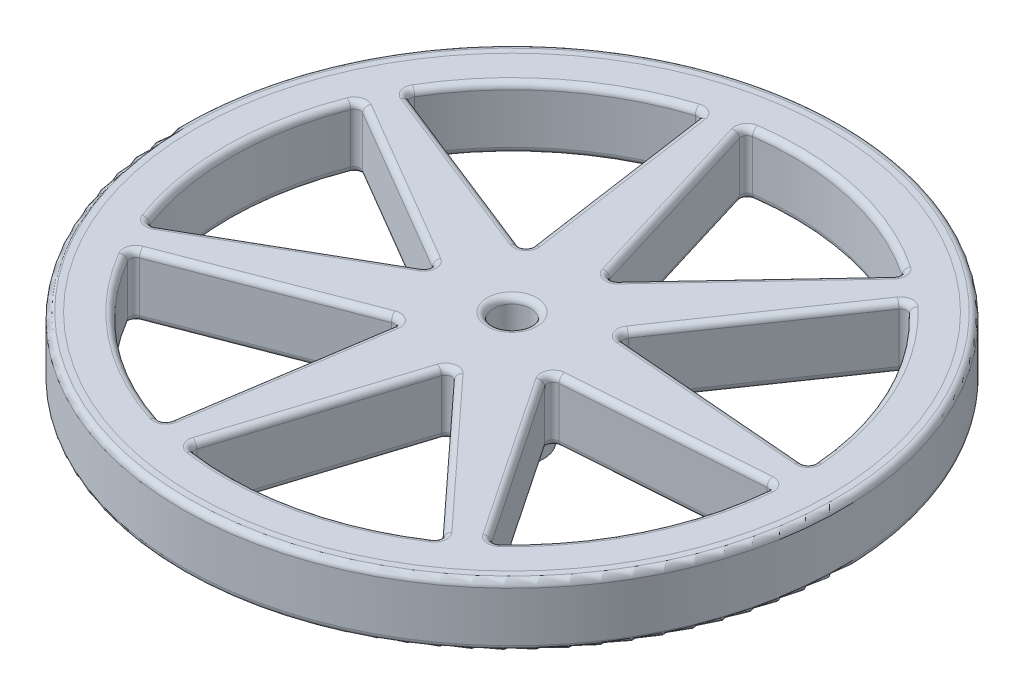
from build123d import *

# Parameters (mm, degrees)
SKETCH1_R               = 53
SKETCH1_R_2             = 52
BOSS_EXTRUDE1_DEPTH     = 10
SKETCH1_3_R             = 52
BOSS_EXTRUDE2_DEPTH     = 10
SKETCH1_4_R             = 5
SKETCH1_4_R_2           = 3
BOSS_EXTRUDE3_DEPTH     = 8
CUT_EXTRUDE1_DEPTH      = 76.617458302
CIRPATTERN1_COUNT       = 7
CUT_EXTRUDE2_DEPTH      = 76.617458302
CUT_EXTRUDE2_DEPTH_BACK = 76.617458302
SKETCH1_5_R             = 3
FILLET2_R               = 1


with BuildPart() as part:
    # Sketch1 → Boss-Extrude1 (new body)
    with BuildSketch(Plane(origin=(0, 0, 0), x_dir=(1, 0, 0), z_dir=(0, 1, 0))):
        Circle(SKETCH1_R)
        Circle(SKETCH1_R_2, mode=Mode.SUBTRACT)
    extrude(amount=BOSS_EXTRUDE1_DEPTH)

    # Sketch1_3 → Boss-Extrude2 (add)
    with BuildSketch(Plane(origin=(0, 0, 0), x_dir=(1, 0, 0), z_dir=(0, 1, 0))):
        Circle(SKETCH1_3_R)
    extrude(amount=BOSS_EXTRUDE2_DEPTH)

    # Sketch1_4 → Boss-Extrude3 (add)
    with BuildSketch(Plane(origin=(0, 0, 0), x_dir=(1, 0, 0), z_dir=(0, 1, 0))):
        Circle(SKETCH1_4_R)
        Circle(SKETCH1_4_R_2, mode=Mode.SUBTRACT)
    extrude(amount=-BOSS_EXTRUDE3_DEPTH)

    # Sketch4 → Cut-Extrude1 (cut, through all)
    with BuildSketch(Plane.XZ):
        with BuildLine():
            Line((-12.210435355, 0), (-41.876278498, 16.995844181))
            ThreePointArc((-41.876278498, 16.995844181), (-45.193490077, -0.172843505), (-41.745053406, -17.315655818))
            Line((-41.745053406, -17.315655818), (-12.210435355, 0))
        make_face()
    cut_extrude1 = extrude(amount=-CUT_EXTRUDE1_DEPTH, mode=Mode.SUBTRACT)

    # CirPattern1: Cut-Extrude1 ×7 about axis
    cirpattern1_axis = Axis((0, 0, 0), (0, 1, 0))
    for i in range(1, CIRPATTERN1_COUNT):
        add(cut_extrude1.rotate(cirpattern1_axis, i * 360 / CIRPATTERN1_COUNT), mode=Mode.SUBTRACT)

    # Sketch1_5 → Cut-Extrude2 (cut, two sides: drawn at the far end of the back side and taken through both)
    with BuildSketch(Plane(origin=(0, 0, 0), x_dir=(1, 0, 0), z_dir=(0, 1, 0)).offset(-CUT_EXTRUDE2_DEPTH_BACK)):
        Circle(SKETCH1_5_R)
    extrude(amount=CUT_EXTRUDE2_DEPTH + CUT_EXTRUDE2_DEPTH_BACK, mode=Mode.SUBTRACT)

    # Fillet2
    fillet2_edges = [part.edges().sort_by_distance(p)[0] for p in [
        (-27.043356926, 10, 8.49792209),
        (-53, 10, 0),
        (-53, 0, 0),
        (-5, 0, 0),
        (-41.745053406, 5, -17.315655818),
        (-41.876278498, 5, 16.995844181),
        (-12.210435355, 5, 0),
        (-45.193490077, 10, -0.172843505),
        (-26.97774438, 10, -8.657827909),
        (-45.193490077, 0, -0.172843505),
        (-27.043356926, 0, 8.49792209),
        (-26.97774438, 0, -8.657827909),
        (-39.565539935, 5, 21.841462175),
        (-12.821546532, 5, 43.336928419),
        (-7.61308192, 5, 9.546502775),
        (-28.312814667, 10, 35.225927183),
        (-10.217314226, 10, 26.441715597),
        (-23.589310927, 10, 15.693982475),
        (-28.312814667, 0, 35.225927183),
        (-10.217314226, 0, 26.441715597),
        (-23.589310927, 0, 15.693982475),
        (-7.592367903, 5, 44.551513665),
        (25.888071485, 5, 37.044421646),
        (2.717077479, 5, 11.904294247),
        (9.887987664, 10, 44.098856223),
        (14.302574482, 10, 24.474357946),
        (-2.437645212, 10, 28.227903956),
        (9.887987664, 0, 44.098856223),
        (14.302574482, 0, 24.474357946),
        (-2.437645212, 0, 28.227903956),
        (30.098012016, 5, 33.713366681),
        (45.103443653, 5, 2.856709805),
        (11.001222118, 5, 5.297909348),
        (40.642933605, 10, 19.764447075),
        (28.052332885, 10, 4.077309576),
        (20.549617067, 10, 19.505638014),
        (40.642933605, 0, 19.764447075),
        (28.052332885, 0, 4.077309576),
        (20.549617067, 0, 19.505638014),
        (45.123974999, 5, -2.511633042),
        (30.355002808, 5, -33.482162785),
        (11.001222118, 5, -5.297909348),
        (40.792921578, 10, -19.452993842),
        (20.678112463, 10, -19.390036067),
        (28.062598559, 10, -3.904771195),
        (40.792921578, 0, -19.452993842),
        (20.678112463, 0, -19.390036067),
        (28.062598559, 0, -3.904771195),
        (26.170664447, 5, -36.845321856),
        (-7.251374281, 5, -44.608283886),
        (2.717077479, 5, -11.904294247),
        (10.225007578, 10, -44.021933627),
        (-2.267148401, 10, -28.256289067),
        (14.443870963, 10, -24.374808052),
        (10.225007578, 0, -44.021933627),
        (-2.267148401, 0, -28.256289067),
        (14.443870963, 0, -24.374808052),
        (-12.489690218, 5, -43.433731805),
        (-39.397318635, 5, -22.143457378),
        (-7.61308192, 5, -9.546502775),
        (-28.04254568, 10, -35.441459508),
        (-23.505200277, 10, -15.844980076),
        (-10.051386069, 10, -26.49011729),
        (-28.04254568, 0, -35.441459508),
        (-23.505200277, 0, -15.844980076),
        (-10.051386069, 0, -26.49011729),
        (-3, 10, 0),
    ]]
    fillet(fillet2_edges, radius=FILLET2_R)


solid = part.part
